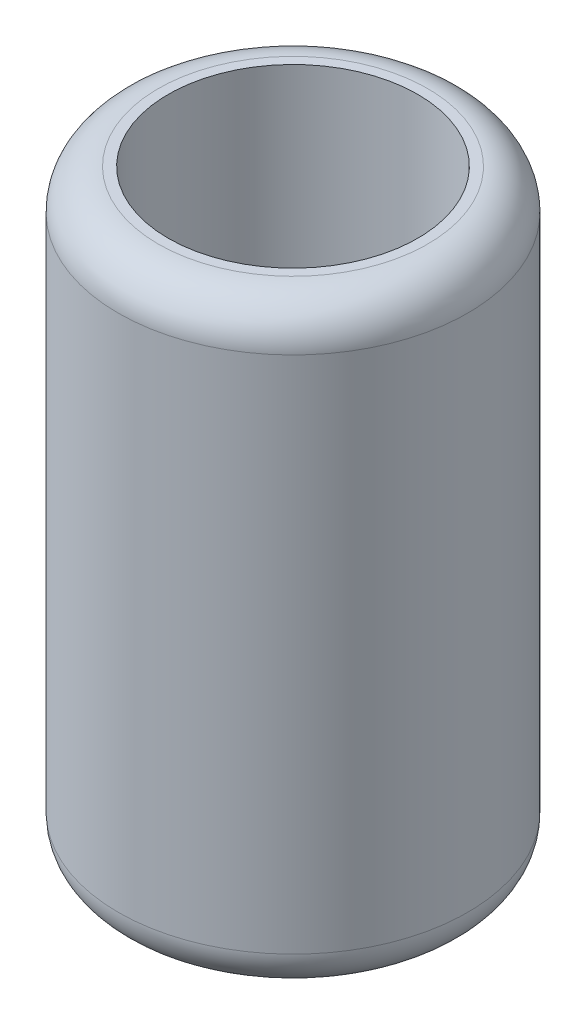
from build123d import *

# Parameters (mm, degrees)
SKETCH1_R           = 11.1125
BOSS_EXTRUDE1_DEPTH = 38.1
SKETCH2_R           = 7.9375
CUT_EXTRUDE1_DEPTH  = 39.1
FILLET2_R           = 2.54


with BuildPart() as part:
    # Sketch1 → Boss-Extrude1 (new body)
    with BuildSketch(Plane(origin=(0, 0, 0), x_dir=(1, 0, 0), z_dir=(0, 1, 0))):
        Circle(SKETCH1_R)
    extrude(amount=BOSS_EXTRUDE1_DEPTH)

    # Sketch2 → Cut-Extrude1 (cut, through all)
    with BuildSketch(Plane(origin=(0, 38.1, 0), x_dir=(1, 0, 0), z_dir=(0, 1, 0))):
        Circle(SKETCH2_R)
    extrude(amount=-CUT_EXTRUDE1_DEPTH, mode=Mode.SUBTRACT)

    # Fillet2
    fillet2_edges = [part.edges().sort_by_distance(p)[0] for p in [
        (-11.1125, 0, 0),
        (-11.1125, 38.1, 0),
    ]]
    fillet(fillet2_edges, radius=FILLET2_R)


solid = part.part
